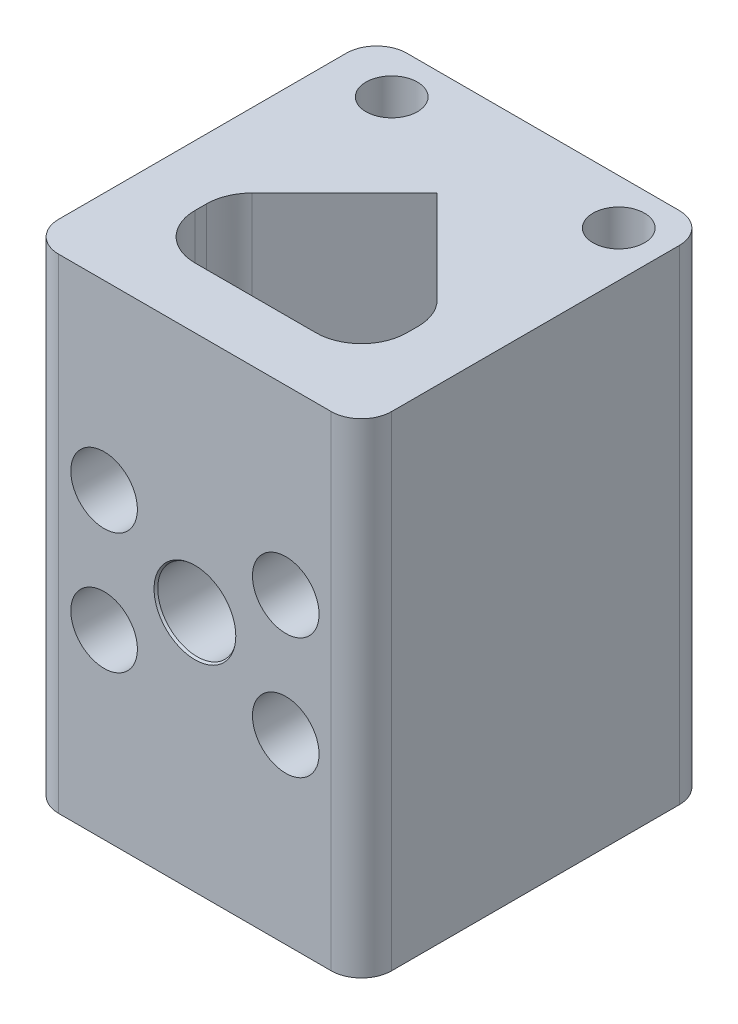
from build123d import *

# Parameters (mm, degrees)
SKETCH1_W                       = 22
SKETCH1_H                       = 23
BOSS_EXTRUDE1_DEPTH             = 32
FILLET1_R                       = 3
CBORE_FOR_M2_SHCS1_D            = 2.4
CBORE_FOR_M2_SHCS1_CBORE_D      = 4.4
CBORE_FOR_M2_SHCS1_CBORE_DEPTH  = 21
F_5_0MM_DOWEL_HOLE1_D           = 5.2
F_5_0MM_DOWEL_HOLE1_DEPTH       = 4
F_5_0MM_DOWEL_HOLE1_CSINK_D     = 5.4
F_5_0MM_DOWEL_HOLE1_CSINK_ANGLE = 70
FILLET2_R                       = 2
M3_CLEARANCE_HOLE1_D            = 3.4
M3_CLEARANCE_HOLE1_DEPTH        = 7.5
M3_CLEARANCE_HOLE1_TIP          = 1.021463052


with BuildPart() as part:
    # Sketch1 → Boss-Extrude1 (new body)
    with BuildSketch(Plane(origin=(0, 0, 0), x_dir=(1, 0, 0), z_dir=(0, 1, 0))):
        with Locations((11, 11.5)):
            Rectangle(SKETCH1_W, SKETCH1_H)
        Polygon((4, 4), (18, 4), (18, 9), (11, 16), (4, 9), align=None, mode=Mode.SUBTRACT)
    extrude(amount=BOSS_EXTRUDE1_DEPTH)

    # Fillet1
    fillet1_edges = [part.edges().sort_by_distance(p)[0] for p in [
        (4, 16, -9),
        (4, 16, -4),
        (18, 16, -4),
        (18, 16, -9),
    ]]
    fillet(fillet1_edges, radius=FILLET1_R)

    # CBORE for M2 SHCS1 (through all)
    with Locations(Plane.XY):
        with Locations((5, 12), (17, 12), (17, 20), (5, 20)):
            CounterBoreHole(CBORE_FOR_M2_SHCS1_D / 2, CBORE_FOR_M2_SHCS1_CBORE_D / 2, CBORE_FOR_M2_SHCS1_CBORE_DEPTH)

    # Ø5.0mm Dowel Hole1
    with Locations(Plane.XY):
        with Locations((11, 16)):
            CounterSinkHole(F_5_0MM_DOWEL_HOLE1_D / 2, F_5_0MM_DOWEL_HOLE1_CSINK_D / 2, depth=F_5_0MM_DOWEL_HOLE1_DEPTH, counter_sink_angle=F_5_0MM_DOWEL_HOLE1_CSINK_ANGLE)

    # Fillet2
    fillet2_edges = [part.edges().sort_by_distance(p)[0] for p in [
        (0, 16, 0),
        (0, 16, -23),
        (22, 16, -23),
        (22, 16, 0),
    ]]
    fillet(fillet2_edges, radius=FILLET2_R)

    # M3 Clearance Hole1
    with Locations(Plane(origin=(0, 32, 0), x_dir=(1, 0, 0), z_dir=(0, 1, 0))):
        with Locations((4, 20), (19, 20)):
            Hole(M3_CLEARANCE_HOLE1_D / 2, depth=M3_CLEARANCE_HOLE1_DEPTH)
            with Locations((0, 0, -(M3_CLEARANCE_HOLE1_DEPTH + M3_CLEARANCE_HOLE1_TIP / 2))):  # 118° drill point
                Cone(0, M3_CLEARANCE_HOLE1_D / 2, M3_CLEARANCE_HOLE1_TIP, mode=Mode.SUBTRACT)


solid = part.part
